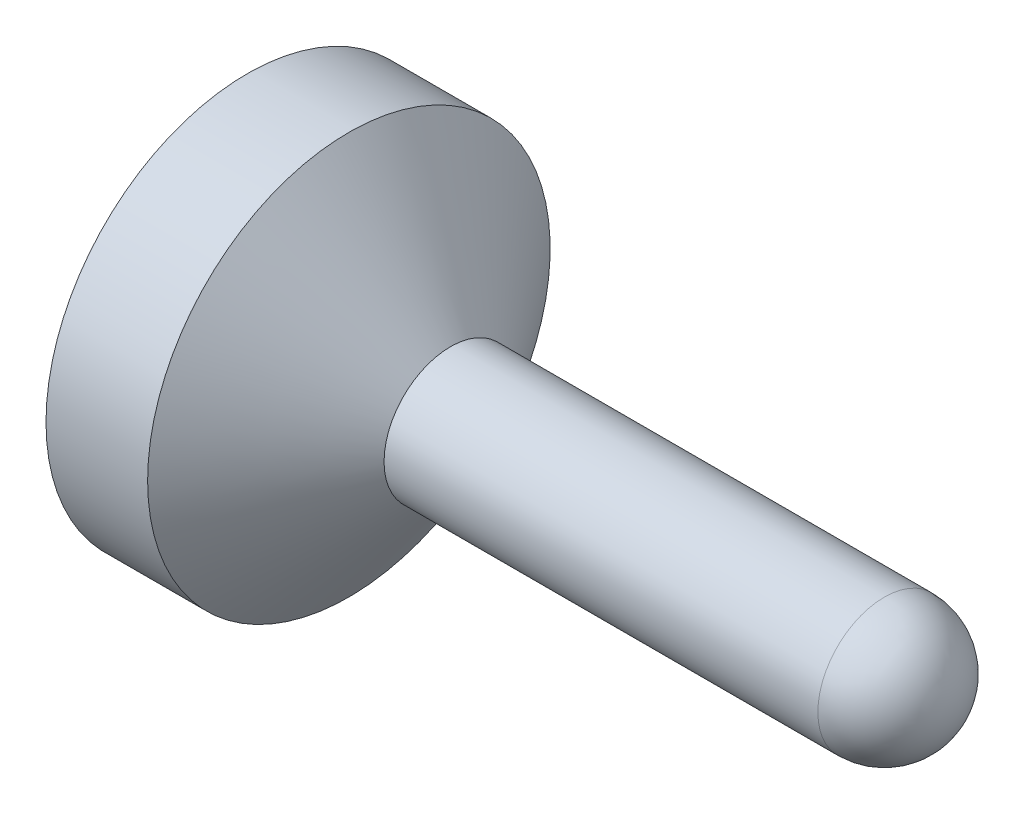
from build123d import *


with BuildPart() as part:
    # Sketch1 → RevolutionAngle1 (revolve)
    with BuildSketch(Plane.XY):
        with BuildLine():
            Line((0, 0), (0, 0.65405))
            Line((0, 0.65405), (0.3302, 0.65405))
            Line((0.3302, 0.65405), (0.660369707, 0.2159))
            Line((0.660369707, 0.2159), (2.0701, 0.2159))
            ThreePointArc((2.0701, 0.2159), (2.222764354, 0.152664354), (2.286, 0))
            Line((2.286, 0), (0, 0))
        make_face()
    revolve(axis=Axis((0, 0, 0), (1, 0, 0)))


solid = part.part
